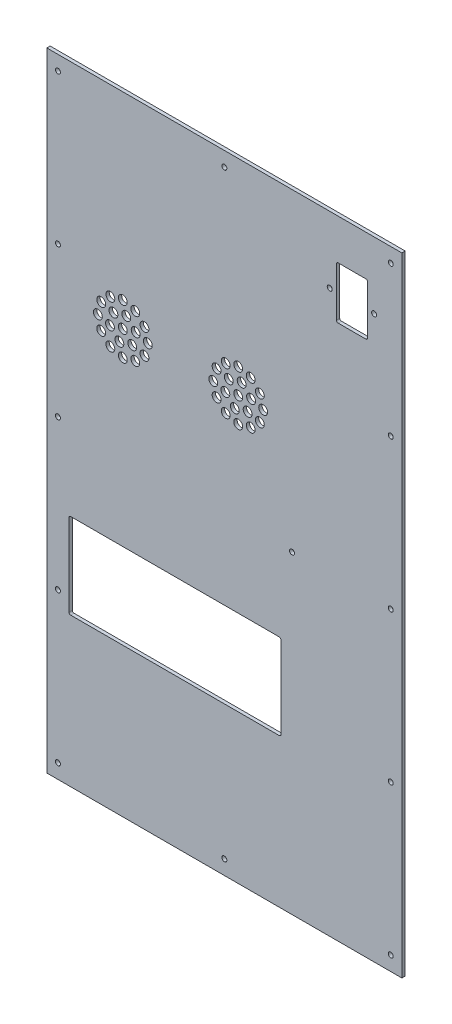
from build123d import *

# Parameters (mm, degrees)
SKETCH_1_W          = 320
SKETCH_1_H          = 566
SKETCH_1_R          = 2.25
EXTRUDE_1_DEPTH     = 3
SKETCH_3_W          = 191
SKETCH_3_H          = 77
CUT_EXTRUDE_2_DEPTH = 4
SKETCH3_R           = 2.25
CUT_EXTRUDE1_DEPTH  = 4
SKETCH_4_R          = 2.25
SKETCH_4_W          = 28
SKETCH_4_H          = 47
CUT_EXTRUDE_3_DEPTH = 4
FILLET_1_R          = 1.5
SKETCH_5_R          = 4
CUT_EXTRUDE_4_DEPTH = 4
FILLET_2_R          = 1.5


with BuildPart() as part:
    # Эскиз1 → Бобышка-Вытянуть1 (new body)
    with BuildSketch(Plane.XY):
        with Locations((160, 283)):
            Rectangle(SKETCH_1_W, SKETCH_1_H)
        with Locations((10, 553)):
            Circle(SKETCH_1_R, mode=Mode.SUBTRACT)
        with Locations((10, 418)):
            Circle(SKETCH_1_R, mode=Mode.SUBTRACT)
        with Locations((10, 283)):
            Circle(SKETCH_1_R, mode=Mode.SUBTRACT)
        with Locations((10, 148)):
            Circle(SKETCH_1_R, mode=Mode.SUBTRACT)
        with Locations((10, 13)):
            Circle(SKETCH_1_R, mode=Mode.SUBTRACT)
        with Locations((310, 13)):
            Circle(SKETCH_1_R, mode=Mode.SUBTRACT)
        with Locations((160, 553)):
            Circle(SKETCH_1_R, mode=Mode.SUBTRACT)
        with Locations((310, 553)):
            Circle(SKETCH_1_R, mode=Mode.SUBTRACT)
        with Locations((310, 418)):
            Circle(SKETCH_1_R, mode=Mode.SUBTRACT)
        with Locations((310, 283)):
            Circle(SKETCH_1_R, mode=Mode.SUBTRACT)
        with Locations((310, 148)):
            Circle(SKETCH_1_R, mode=Mode.SUBTRACT)
        with Locations((160, 13)):
            Circle(SKETCH_1_R, mode=Mode.SUBTRACT)
    extrude(amount=EXTRUDE_1_DEPTH)

    # Эскиз3 → Вырез-Вытянуть2 (cut, through all)
    with BuildSketch(Plane(origin=(0, 0, 0), x_dir=(-1, 0, 0), z_dir=(0, 0, -1))):
        with Locations((-115.5, 172.5)):
            Rectangle(SKETCH_3_W, SKETCH_3_H)
    extrude(amount=-CUT_EXTRUDE_2_DEPTH, mode=Mode.SUBTRACT)

    # Sketch3 → Cut-Extrude1 (cut, through all)
    with BuildSketch(Plane(origin=(0, 0, 0), x_dir=(-1, 0, 0), z_dir=(0, 0, -1))):
        with Locations((-101, 163)):
            Circle(SKETCH3_R)
        with Locations((-221, 283)):
            Circle(SKETCH3_R)
    extrude(amount=-CUT_EXTRUDE1_DEPTH, mode=Mode.SUBTRACT)

    # Эскиз4 → Вырез-Вытянуть3 (cut, through all)
    with BuildSketch(Plane.XY.offset(3)):
        with Locations((255, 506)):
            Circle(SKETCH_4_R)
        with Locations((295, 506)):
            Circle(SKETCH_4_R)
        with Locations((275, 506)):
            Rectangle(SKETCH_4_W, SKETCH_4_H)
    extrude(amount=-CUT_EXTRUDE_3_DEPTH, mode=Mode.SUBTRACT)

    # Скругление1
    fillet_1_edges = [part.edges().sort_by_distance(p)[0] for p in [
        (211, 211, 1.5),
        (20, 211, 1.5),
        (20, 134, 1.5),
        (211, 134, 1.5),
    ]]
    fillet(fillet_1_edges, radius=FILLET_1_R)

    # Эскиз5 → Вырез-Вытянуть4 (cut, through all)
    with BuildSketch(Plane(origin=(0, 0, 0), x_dir=(-1, 0, 0), z_dir=(0, 0, -1))):
        with Locations((-172.5, 381)):
            Circle(SKETCH_5_R)
        with Locations((-172.5, 358.5)):
            Circle(SKETCH_5_R)
        with Locations((-180.985281374, 372.514718626)):
            Circle(SKETCH_5_R)
        with Locations((-183.75, 361.514428415)):
            Circle(SKETCH_5_R)
        with Locations((-191.985571585, 369.75)):
            Circle(SKETCH_5_R)
        with Locations((-195, 381)):
            Circle(SKETCH_5_R)
        with Locations((-191.985571585, 392.25)):
            Circle(SKETCH_5_R)
        with Locations((-183.75, 400.485571585)):
            Circle(SKETCH_5_R)
        with Locations((-172.5, 403.5)):
            Circle(SKETCH_5_R)
        with Locations((-161.25, 400.485571585)):
            Circle(SKETCH_5_R)
        with Locations((-153.014428415, 392.25)):
            Circle(SKETCH_5_R)
        with Locations((-150, 381)):
            Circle(SKETCH_5_R)
        with Locations((-153.014428415, 369.75)):
            Circle(SKETCH_5_R)
        with Locations((-161.25, 361.514428415)):
            Circle(SKETCH_5_R)
        with Locations((-184.091109915, 384.105828541)):
            Circle(SKETCH_5_R)
        with Locations((-175.605828541, 392.591109915)):
            Circle(SKETCH_5_R)
        with Locations((-164.014718626, 389.485281374)):
            Circle(SKETCH_5_R)
        with Locations((-160.908890085, 377.894171459)):
            Circle(SKETCH_5_R)
        with Locations((-169.394171459, 369.408890085)):
            Circle(SKETCH_5_R)
        with Locations((-68.5, 381)):
            Circle(SKETCH_5_R)
        with Locations((-68.5, 358.5)):
            Circle(SKETCH_5_R)
        with Locations((-76.985281374, 372.514718626)):
            Circle(SKETCH_5_R)
        with Locations((-79.75, 361.514428415)):
            Circle(SKETCH_5_R)
        with Locations((-87.985571585, 369.75)):
            Circle(SKETCH_5_R)
        with Locations((-91, 381)):
            Circle(SKETCH_5_R)
        with Locations((-87.985571585, 392.25)):
            Circle(SKETCH_5_R)
        with Locations((-79.75, 400.485571585)):
            Circle(SKETCH_5_R)
        with Locations((-68.5, 403.5)):
            Circle(SKETCH_5_R)
        with Locations((-57.25, 400.485571585)):
            Circle(SKETCH_5_R)
        with Locations((-49.014428415, 392.25)):
            Circle(SKETCH_5_R)
        with Locations((-46, 381)):
            Circle(SKETCH_5_R)
        with Locations((-49.014428415, 369.75)):
            Circle(SKETCH_5_R)
        with Locations((-57.25, 361.514428415)):
            Circle(SKETCH_5_R)
        with Locations((-80.091109915, 384.105828541)):
            Circle(SKETCH_5_R)
        with Locations((-71.605828541, 392.591109915)):
            Circle(SKETCH_5_R)
        with Locations((-60.014718626, 389.485281374)):
            Circle(SKETCH_5_R)
        with Locations((-56.908890085, 377.894171459)):
            Circle(SKETCH_5_R)
        with Locations((-65.394171459, 369.408890085)):
            Circle(SKETCH_5_R)
    extrude(amount=-CUT_EXTRUDE_4_DEPTH, mode=Mode.SUBTRACT)

    # Скругление2
    fillet_2_edges = [part.edges().sort_by_distance(p)[0] for p in [
        (261, 482.5, 1.5),
        (261, 529.5, 1.5),
        (289, 529.5, 1.5),
        (289, 482.5, 1.5),
    ]]
    fillet(fillet_2_edges, radius=FILLET_2_R)


solid = part.part
